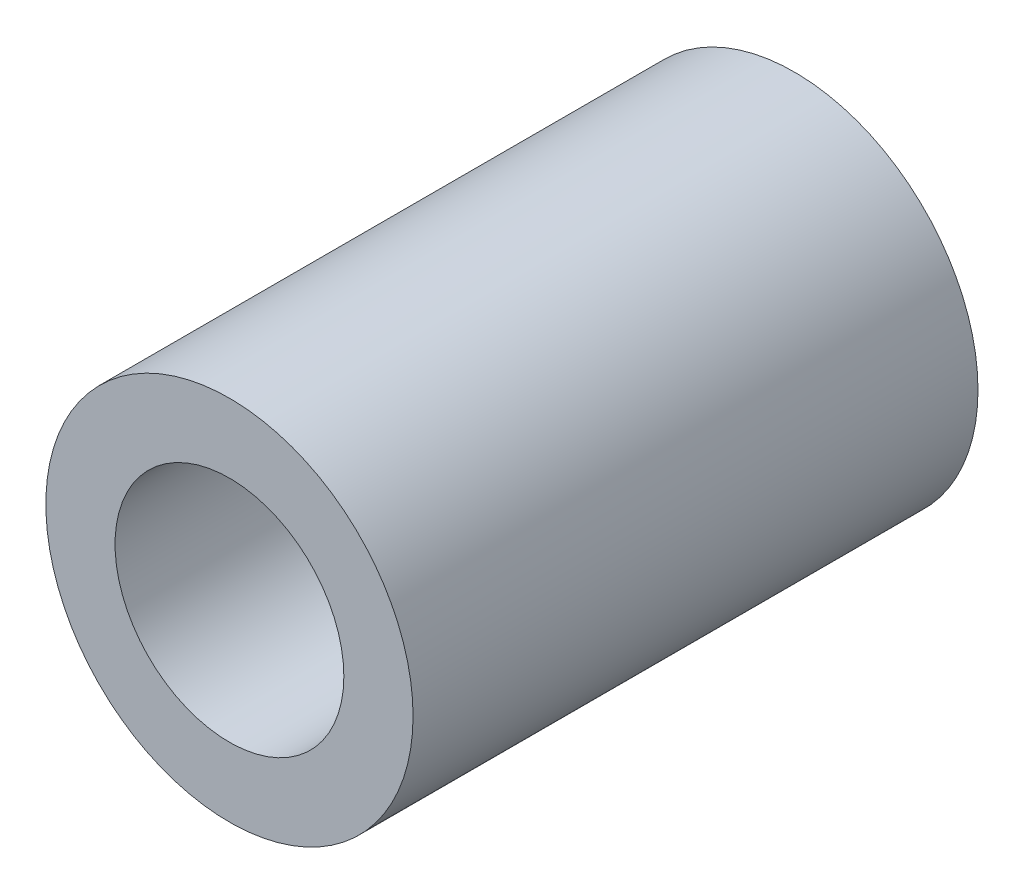
from build123d import *

# Parameters (mm, degrees)
CROQUIS1_R              = 6.5
CROQUIS1_R_2            = 4.05
SALIENTE_EXTRUIR1_DEPTH = 20


with BuildPart() as part:
    # Croquis1 → Saliente-Extruir1 (new body)
    with BuildSketch(Plane.XY):
        Circle(CROQUIS1_R)
        Circle(CROQUIS1_R_2, mode=Mode.SUBTRACT)
    extrude(amount=SALIENTE_EXTRUIR1_DEPTH)


solid = part.part
